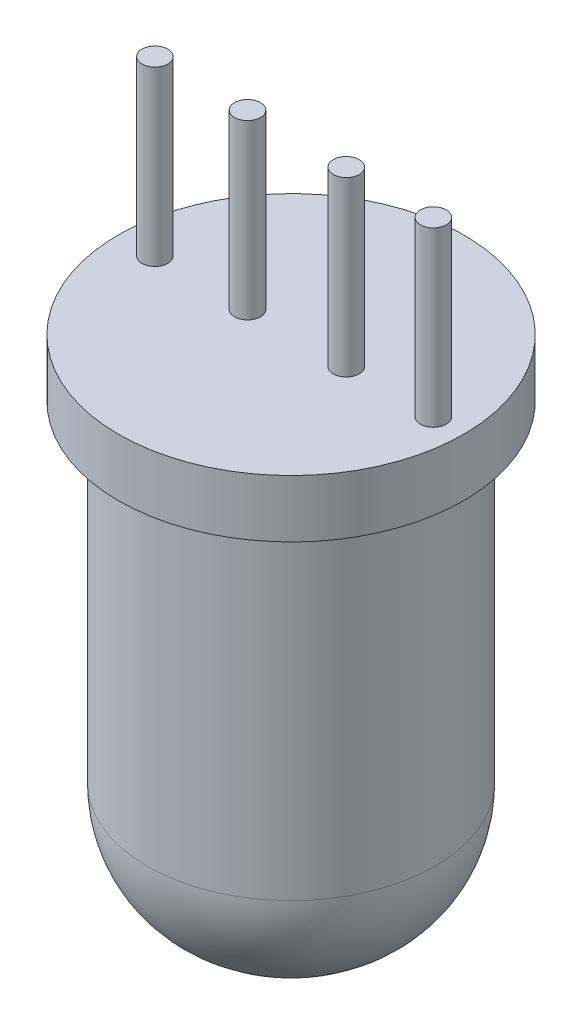
from build123d import *

# Parameters (mm, degrees)
SKETCH1_R           = 2.5
BOSS_EXTRUDE1_DEPTH = 9
SKETCH2_R           = 3
BOSS_EXTRUDE3_DEPTH = 1
FILLET3_R           = 2.25
SKETCH4_R           = 0.224891602
BOSS_EXTRUDE4_DEPTH = 3


with BuildPart() as part:
    # Sketch1 → Boss-Extrude1 (new body)
    with BuildSketch(Plane(origin=(0, 0, 0), x_dir=(1, 0, 0), z_dir=(0, 1, 0))):
        with Locations(Location((0, 0, 0), (0, 0, 270))):  # turned: the seam where the file's is
            Circle(SKETCH1_R)
    extrude(amount=BOSS_EXTRUDE1_DEPTH)

    # Sketch2 → Boss-Extrude3 (add)
    with BuildSketch(Plane(origin=(0, 9, 0), x_dir=(1, 0, 0), z_dir=(0, 1, 0))):
        with Locations(Location((0, 0, 0), (0, 0, 270))):  # turned: the seam where the file's is
            Circle(SKETCH2_R)
    extrude(amount=-BOSS_EXTRUDE3_DEPTH)

    # Fillet3
    fillet3_edges = [part.edges().sort_by_distance(p)[0] for p in [
        (0, 0, -2.5),
    ]]
    fillet(fillet3_edges, radius=FILLET3_R)

    # Sketch4 → Boss-Extrude4 (add)
    with BuildSketch(Plane(origin=(0, 9, 0), x_dir=(1, 0, 0), z_dir=(0, 1, 0))):
        with Locations(Location((-2.366051797, 0, 0), (0, 0, 270))):  # turned: the seam where the file's is
            Circle(SKETCH4_R)
        with Locations(Location((-0.756710259, 0, 0), (0, 0, 270))):  # turned: the seam where the file's is
            Circle(SKETCH4_R)
        with Locations(Location((0.959210188, 0, 0), (0, 0, 270))):  # turned: the seam where the file's is
            Circle(SKETCH4_R)
        with Locations(Location((2.472630707, 0, 0), (0, 0, 270))):  # turned: the seam where the file's is
            Circle(SKETCH4_R)
    extrude(amount=BOSS_EXTRUDE4_DEPTH)


solid = part.part
